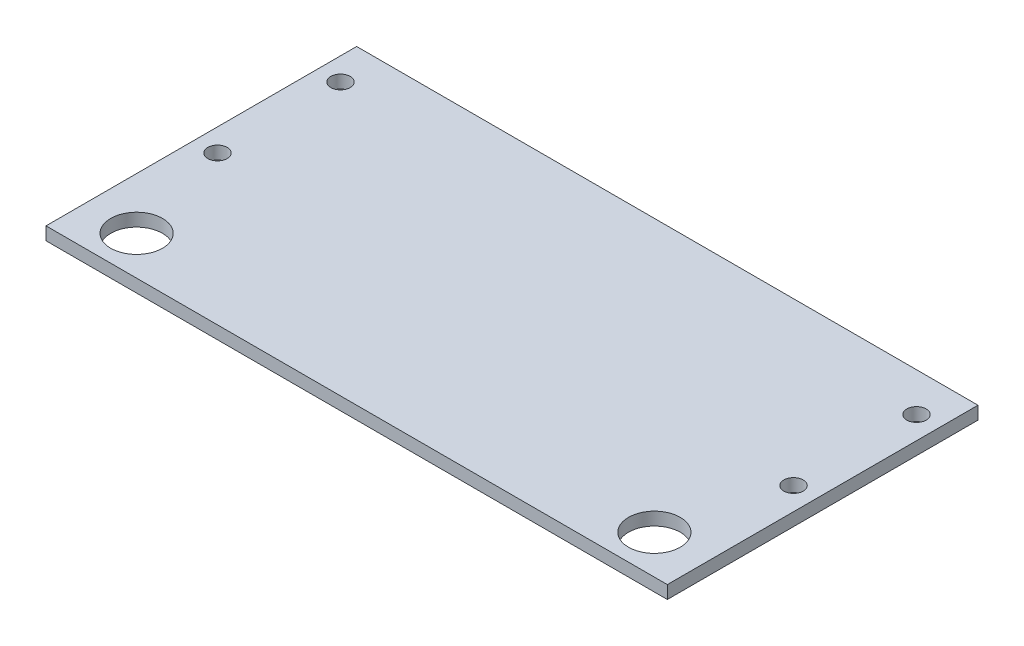
from build123d import *

# Parameters (mm, degrees)
SKETCH1_W           = 304.8
SKETCH1_H           = 152.4
BOSS_EXTRUDE1_DEPTH = 6.35
CUT_EXTRUDE1_REACH  = 8.35
SKETCH2_R           = 12.7
SKETCH2_R_2         = 4.7625


with BuildPart() as part:
    # Sketch1 → Boss-Extrude1 (new body)
    with BuildSketch(Plane(origin=(0, 0, 0), x_dir=(1, 0, 0), z_dir=(0, 1, 0))):
        with Locations((152.4, 76.2)):
            Rectangle(SKETCH1_W, SKETCH1_H)
    extrude(amount=BOSS_EXTRUDE1_DEPTH)

    # Sketch2 → Cut-Extrude1 (cut, up to next)
    with BuildSketch(Plane(origin=(0, 6.35, 0), x_dir=(-1, 0, 0), z_dir=(0, 1, 0)), mode=Mode.PRIVATE) as cut_extrude1_sk1:
        with Locations((-25.4, -19.05)):
            Circle(SKETCH2_R)
    cut_extrude1_tool1 = extrude(cut_extrude1_sk1.sketch, amount=-CUT_EXTRUDE1_REACH, mode=Mode.PRIVATE) & part.part
    add(cut_extrude1_tool1.solids().sort_by_distance((25.4, 6.35, -19.05))[0], mode=Mode.SUBTRACT)
    # Sketch2 → Cut-Extrude1 (cut, up to next)
    with BuildSketch(Plane(origin=(0, 6.35, 0), x_dir=(-1, 0, 0), z_dir=(0, 1, 0)), mode=Mode.PRIVATE) as cut_extrude1_sk2:
        with Locations((-293.6875, -133.35)):
            Circle(SKETCH2_R_2)
    cut_extrude1_tool2 = extrude(cut_extrude1_sk2.sketch, amount=-CUT_EXTRUDE1_REACH, mode=Mode.PRIVATE) & part.part
    add(cut_extrude1_tool2.solids().sort_by_distance((293.6875, 6.35, -133.35))[0], mode=Mode.SUBTRACT)
    # Sketch2 → Cut-Extrude1 (cut, up to next)
    with BuildSketch(Plane(origin=(0, 6.35, 0), x_dir=(-1, 0, 0), z_dir=(0, 1, 0)), mode=Mode.PRIVATE) as cut_extrude1_sk3:
        with Locations((-11.1125, -133.35)):
            Circle(SKETCH2_R_2)
    cut_extrude1_tool3 = extrude(cut_extrude1_sk3.sketch, amount=-CUT_EXTRUDE1_REACH, mode=Mode.PRIVATE) & part.part
    add(cut_extrude1_tool3.solids().sort_by_distance((11.1125, 6.35, -133.35))[0], mode=Mode.SUBTRACT)
    # Sketch2 → Cut-Extrude1 (cut, up to next)
    with BuildSketch(Plane(origin=(0, 6.35, 0), x_dir=(-1, 0, 0), z_dir=(0, 1, 0)), mode=Mode.PRIVATE) as cut_extrude1_sk4:
        with Locations((-11.1125, -73.025)):
            Circle(SKETCH2_R_2)
    cut_extrude1_tool4 = extrude(cut_extrude1_sk4.sketch, amount=-CUT_EXTRUDE1_REACH, mode=Mode.PRIVATE) & part.part
    add(cut_extrude1_tool4.solids().sort_by_distance((11.1125, 6.35, -73.025))[0], mode=Mode.SUBTRACT)
    # Sketch2 → Cut-Extrude1 (cut, up to next)
    with BuildSketch(Plane(origin=(0, 6.35, 0), x_dir=(-1, 0, 0), z_dir=(0, 1, 0)), mode=Mode.PRIVATE) as cut_extrude1_sk5:
        with Locations((-293.6875, -73.025)):
            Circle(SKETCH2_R_2)
    cut_extrude1_tool5 = extrude(cut_extrude1_sk5.sketch, amount=-CUT_EXTRUDE1_REACH, mode=Mode.PRIVATE) & part.part
    add(cut_extrude1_tool5.solids().sort_by_distance((293.6875, 6.35, -73.025))[0], mode=Mode.SUBTRACT)
    # Sketch2 → Cut-Extrude1 (cut, up to next)
    with BuildSketch(Plane(origin=(0, 6.35, 0), x_dir=(-1, 0, 0), z_dir=(0, 1, 0)), mode=Mode.PRIVATE) as cut_extrude1_sk6:
        with Locations((-279.4, -19.05)):
            Circle(SKETCH2_R)
    cut_extrude1_tool6 = extrude(cut_extrude1_sk6.sketch, amount=-CUT_EXTRUDE1_REACH, mode=Mode.PRIVATE) & part.part
    add(cut_extrude1_tool6.solids().sort_by_distance((279.4, 6.35, -19.05))[0], mode=Mode.SUBTRACT)


solid = part.part
